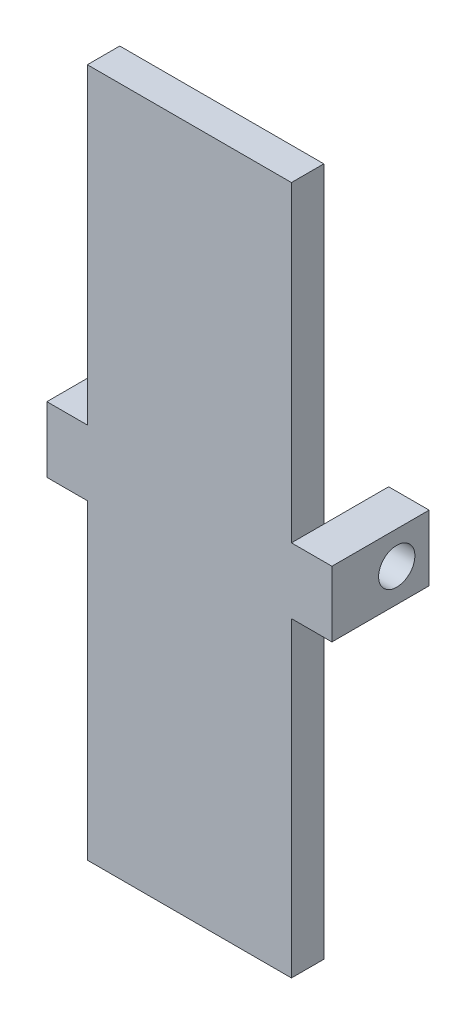
from build123d import *

# Parameters (mm, degrees)
SKETCH1_W           = 16
SKETCH1_H           = 54.011330832
BOSS_EXTRUDE1_DEPTH = 2.54
SKETCH2_W           = 7.62
SKETCH2_H           = 5.141453329
SKETCH2_R           = 1.4224
BOSS_EXTRUDE2_DEPTH = 3.175


with BuildPart() as part:
    # Sketch1 → Boss-Extrude1 (new body)
    with BuildSketch(Plane.XY):
        with Locations((-8, 27.005665416)):
            Rectangle(SKETCH1_W, SKETCH1_H)
    extrude(amount=BOSS_EXTRUDE1_DEPTH)

    # Sketch2 → Boss-Extrude2 (add)
    with BuildSketch(Plane(origin=(0, 0, 0), x_dir=(0, 0, -1), z_dir=(1, 0, 0))):
        with Locations((1.27, 26.974938752)):
            Rectangle(SKETCH2_W, SKETCH2_H)
        with Locations((2.54, 27.005665416)):
            Circle(SKETCH2_R, mode=Mode.SUBTRACT)
    boss_extrude2 = extrude(amount=BOSS_EXTRUDE2_DEPTH)

    # Mirror1: Boss-Extrude2 across plane
    add(boss_extrude2.mirror(Plane.ZY.offset(8)))


solid = part.part
